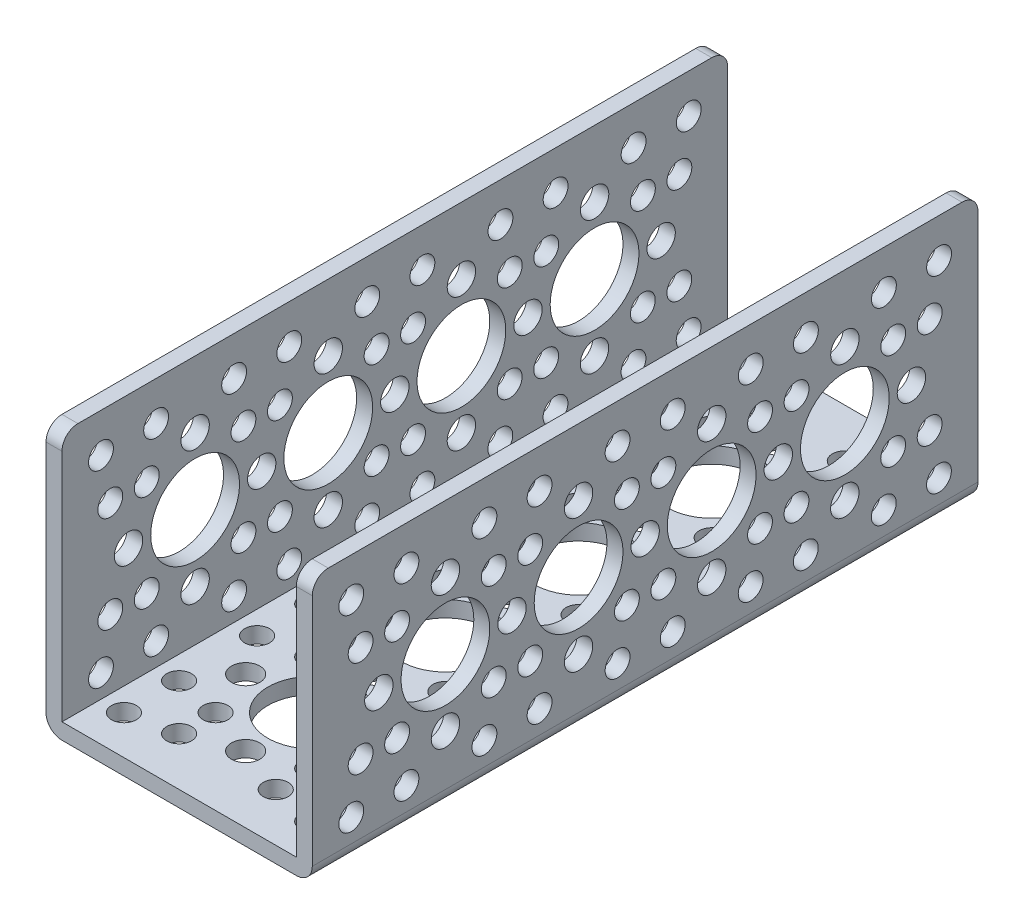
from build123d import *

# Parameters (mm, degrees)
EXTRUDE_THIN1_DEPTH = 95.25
SKETCH3_R           = 6.35
SKETCH3_R_2         = 2.032
SKETCH3_R_3         = 1.778
CUT_EXTRUDE1_DEPTH  = 2.286
SKETCH4_R           = 6.35
SKETCH4_R_2         = 2.032
SKETCH4_R_3         = 1.778
CUT_EXTRUDE2_DEPTH  = 39.1
FILLET1_R           = 2.286


with BuildPart() as part:
    # Sketch1 → Extrude-Thin1 (new body)
    with BuildSketch(Plane.XY):
        Polygon((0, 38.1), (0, 0), (38.1, 0), (38.1, 38.1), (35.814, 38.1), (35.814, 2.286), (2.286, 2.286), (2.286, 38.1), align=None)
    extrude(amount=EXTRUDE_THIN1_DEPTH)

    # Sketch3 → Cut-Extrude1 (cut)
    with BuildSketch(Plane.XZ):
        with Locations((19.05, 38.108384182)):
            Circle(SKETCH3_R)
        with Locations((9.525, 38.108384182)):
            Circle(SKETCH3_R_2)
        with Locations((28.575, 38.108384182)):
            Circle(SKETCH3_R_2)
        with Locations((19.05, 57.158384182)):
            Circle(SKETCH3_R)
        with Locations((9.525, 57.158384182)):
            Circle(SKETCH3_R_2)
        with Locations((28.575, 57.158384182)):
            Circle(SKETCH3_R_2)
        with Locations((19.05, 47.625)):
            Circle(SKETCH3_R_2)
        with Locations((25.964797213, 50.235202787)):
            Circle(SKETCH3_R_3)
        with Locations((32.520384182, 43.679615818)):
            Circle(SKETCH3_R_3)
        with Locations((12.135202787, 50.235202787)):
            Circle(SKETCH3_R_3)
        with Locations((5.579615818, 43.679615818)):
            Circle(SKETCH3_R_3)
        with Locations((25.964797213, 45.014797213)):
            Circle(SKETCH3_R_3)
        with Locations((12.135202787, 45.014797213)):
            Circle(SKETCH3_R_3)
        with Locations((32.520384182, 51.570384182)):
            Circle(SKETCH3_R_3)
        with Locations((5.579615818, 51.570384182)):
            Circle(SKETCH3_R_3)
        with Locations((19.05, 19.058384182)):
            Circle(SKETCH3_R)
        with Locations((19.05, 9.533384182)):
            Circle(SKETCH3_R_2)
        with Locations((9.525, 19.058384182)):
            Circle(SKETCH3_R_2)
        with Locations((19.05, 28.583384182)):
            Circle(SKETCH3_R_2)
        with Locations((28.575, 19.058384182)):
            Circle(SKETCH3_R_2)
        with Locations((12.135202787, 25.973181395)):
            Circle(SKETCH3_R_3)
        with Locations((5.579615818, 32.528768363)):
            Circle(SKETCH3_R_3)
        with Locations((25.964797213, 25.973181395)):
            Circle(SKETCH3_R_3)
        with Locations((32.520384182, 32.528768363)):
            Circle(SKETCH3_R_3)
        with Locations((25.964797213, 12.143586968)):
            Circle(SKETCH3_R_3)
        with Locations((32.520384182, 5.588)):
            Circle(SKETCH3_R_3)
        with Locations((12.135202787, 12.143586968)):
            Circle(SKETCH3_R_3)
        with Locations((5.579615818, 5.588)):
            Circle(SKETCH3_R_3)
        with Locations((12.135202787, 31.193586968)):
            Circle(SKETCH3_R_3)
        with Locations((25.964797213, 31.193586968)):
            Circle(SKETCH3_R_3)
        with Locations((25.964797213, 6.923181395)):
            Circle(SKETCH3_R_3)
        with Locations((12.135202787, 6.923181395)):
            Circle(SKETCH3_R_3)
        with Locations((32.520384182, 13.478768363)):
            Circle(SKETCH3_R_3)
        with Locations((5.579615818, 13.478768363)):
            Circle(SKETCH3_R_3)
        with Locations((5.579615818, 24.638)):
            Circle(SKETCH3_R_3)
        with Locations((32.520384182, 24.638)):
            Circle(SKETCH3_R_3)
        with Locations((19.05, 76.208384182)):
            Circle(SKETCH3_R)
        with Locations((19.05, 66.683384182)):
            Circle(SKETCH3_R_2)
        with Locations((9.525, 76.208384182)):
            Circle(SKETCH3_R_2)
        with Locations((19.05, 85.733384182)):
            Circle(SKETCH3_R_2)
        with Locations((28.575, 76.208384182)):
            Circle(SKETCH3_R_2)
        with Locations((12.135202787, 83.123181395)):
            Circle(SKETCH3_R_3)
        with Locations((5.579615818, 89.678768363)):
            Circle(SKETCH3_R_3)
        with Locations((25.964797213, 83.123181395)):
            Circle(SKETCH3_R_3)
        with Locations((32.520384182, 89.678768363)):
            Circle(SKETCH3_R_3)
        with Locations((25.964797213, 69.293586968)):
            Circle(SKETCH3_R_3)
        with Locations((32.520384182, 62.738)):
            Circle(SKETCH3_R_3)
        with Locations((12.135202787, 69.293586968)):
            Circle(SKETCH3_R_3)
        with Locations((5.579615818, 62.738)):
            Circle(SKETCH3_R_3)
        with Locations((12.135202787, 88.343586968)):
            Circle(SKETCH3_R_3)
        with Locations((25.964797213, 88.343586968)):
            Circle(SKETCH3_R_3)
        with Locations((25.964797213, 64.073181395)):
            Circle(SKETCH3_R_3)
        with Locations((12.135202787, 64.073181395)):
            Circle(SKETCH3_R_3)
        with Locations((32.520384182, 70.628768363)):
            Circle(SKETCH3_R_3)
        with Locations((5.579615818, 70.628768363)):
            Circle(SKETCH3_R_3)
        with Locations((5.579615818, 81.788)):
            Circle(SKETCH3_R_3)
        with Locations((32.520384182, 81.788)):
            Circle(SKETCH3_R_3)
    extrude(amount=-CUT_EXTRUDE1_DEPTH, mode=Mode.SUBTRACT)

    # Sketch4 → Cut-Extrude2 (cut, through all)
    with BuildSketch(Plane.ZY):
        with Locations((57.15, 19.05)):
            Circle(SKETCH4_R)
        with Locations((57.15, 28.575)):
            Circle(SKETCH4_R_2)
        with Locations((57.15, 9.525)):
            Circle(SKETCH4_R_2)
        with Locations((38.1, 19.05)):
            Circle(SKETCH4_R)
        with Locations((38.1, 28.575)):
            Circle(SKETCH4_R_2)
        with Locations((38.1, 9.525)):
            Circle(SKETCH4_R_2)
        with Locations((47.625, 19.05)):
            Circle(SKETCH4_R_2)
        with Locations((50.235202787, 12.135202787)):
            Circle(SKETCH4_R_3)
        with Locations((43.679615818, 5.579615818)):
            Circle(SKETCH4_R_3)
        with Locations((50.235202787, 25.964797213)):
            Circle(SKETCH4_R_3)
        with Locations((43.679615818, 32.520384182)):
            Circle(SKETCH4_R_3)
        with Locations((45.014797213, 12.135202787)):
            Circle(SKETCH4_R_3)
        with Locations((45.014797213, 25.964797213)):
            Circle(SKETCH4_R_3)
        with Locations((51.570384182, 5.579615818)):
            Circle(SKETCH4_R_3)
        with Locations((51.570384182, 32.520384182)):
            Circle(SKETCH4_R_3)
        with Locations((76.2, 19.05)):
            Circle(SKETCH4_R)
        with Locations((66.675, 19.05)):
            Circle(SKETCH4_R_2)
        with Locations((76.2, 28.575)):
            Circle(SKETCH4_R_2)
        with Locations((85.725, 19.05)):
            Circle(SKETCH4_R_2)
        with Locations((76.2, 9.525)):
            Circle(SKETCH4_R_2)
        with Locations((83.114797213, 25.964797213)):
            Circle(SKETCH4_R_3)
        with Locations((89.670384182, 32.520384182)):
            Circle(SKETCH4_R_3)
        with Locations((83.114797213, 12.135202787)):
            Circle(SKETCH4_R_3)
        with Locations((89.670384182, 5.579615818)):
            Circle(SKETCH4_R_3)
        with Locations((69.285202787, 12.135202787)):
            Circle(SKETCH4_R_3)
        with Locations((62.729615818, 5.579615818)):
            Circle(SKETCH4_R_3)
        with Locations((69.285202787, 25.964797213)):
            Circle(SKETCH4_R_3)
        with Locations((62.729615818, 32.520384182)):
            Circle(SKETCH4_R_3)
        with Locations((88.335202787, 25.964797213)):
            Circle(SKETCH4_R_3)
        with Locations((88.335202787, 12.135202787)):
            Circle(SKETCH4_R_3)
        with Locations((64.064797213, 12.135202787)):
            Circle(SKETCH4_R_3)
        with Locations((64.064797213, 25.964797213)):
            Circle(SKETCH4_R_3)
        with Locations((70.620384182, 5.579615818)):
            Circle(SKETCH4_R_3)
        with Locations((70.620384182, 32.520384182)):
            Circle(SKETCH4_R_3)
        with Locations((81.779615818, 32.520384182)):
            Circle(SKETCH4_R_3)
        with Locations((81.779615818, 5.579615818)):
            Circle(SKETCH4_R_3)
        with Locations((19.05, 19.05)):
            Circle(SKETCH4_R)
        with Locations((9.525001844, 19.044073332)):
            Circle(SKETCH4_R_2)
        with Locations((19.044073332, 28.574998156)):
            Circle(SKETCH4_R_2)
        with Locations((28.574998156, 19.055926668)):
            Circle(SKETCH4_R_2)
        with Locations((19.055926668, 9.525001844)):
            Circle(SKETCH4_R_2)
        with Locations((25.960493333, 25.969098416)):
            Circle(SKETCH4_R_3)
        with Locations((32.512, 32.528763148)):
            Circle(SKETCH4_R_3)
        with Locations((25.969098416, 12.139506667)):
            Circle(SKETCH4_R_3)
        with Locations((32.528763148, 5.588)):
            Circle(SKETCH4_R_3)
        with Locations((12.139506667, 12.130901584)):
            Circle(SKETCH4_R_3)
        with Locations((5.588, 5.571236852)):
            Circle(SKETCH4_R_3)
        with Locations((12.130901584, 25.960493333)):
            Circle(SKETCH4_R_3)
        with Locations((5.571236852, 32.512)):
            Circle(SKETCH4_R_3)
        with Locations((31.180897896, 25.972346669)):
            Circle(SKETCH4_R_3)
        with Locations((31.189502979, 12.14275492)):
            Circle(SKETCH4_R_3)
        with Locations((6.919102104, 12.127653331)):
            Circle(SKETCH4_R_3)
        with Locations((6.910497021, 25.95724508)):
            Circle(SKETCH4_R_3)
        with Locations((13.478766836, 5.576146664)):
            Circle(SKETCH4_R_3)
        with Locations((13.462003688, 32.516909812)):
            Circle(SKETCH4_R_3)
        with Locations((24.621233164, 32.523853336)):
            Circle(SKETCH4_R_3)
        with Locations((24.637996312, 5.583090188)):
            Circle(SKETCH4_R_3)
    extrude(amount=-CUT_EXTRUDE2_DEPTH, mode=Mode.SUBTRACT)

    # Fillet1
    fillet1_edges = [part.edges().sort_by_distance(p)[0] for p in [
        (38.1, 0, 47.625),
        (0, 0, 47.625),
        (36.957, 38.1, 95.25),
        (1.143, 38.1, 95.25),
        (36.957, 38.1, 0),
        (1.143, 38.1, 0),
    ]]
    fillet(fillet1_edges, radius=FILLET1_R)


solid = part.part
